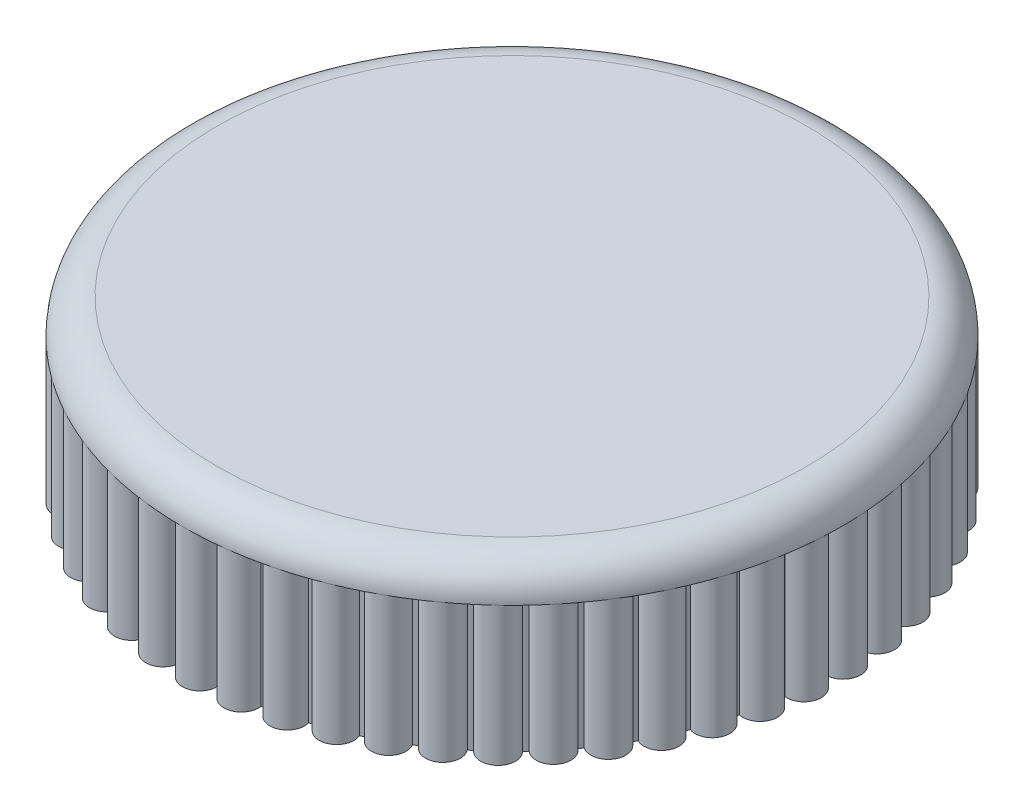
from build123d import *

# Parameters (mm, degrees)
SKETCH1_R           = 24.13
BOSS_EXTRUDE3_DEPTH = 12.7
FILLET2_R           = 2.54
SKETCH4_OUTSIDE_W   = 64.144
SKETCH4_OUTSIDE_H   = 64.144
SKETCH4_OUTSIDE_R   = 22.86
CUT_EXTRUDE3_DEPTH  = 10.16
SKETCH5_R           = 19.05
CUT_EXTRUDE4_DEPTH  = 10.16
SKETCH6_R           = 1.27
BOSS_EXTRUDE7_DEPTH = 10.16
CIRPATTERN1_COUNT   = 50


with BuildPart() as part:
    # Sketch1 → Boss-Extrude3 (new body)
    with BuildSketch(Plane(origin=(0, 0, 0), x_dir=(1, 0, 0), z_dir=(0, 1, 0))):
        Circle(SKETCH1_R)
    extrude(amount=BOSS_EXTRUDE3_DEPTH)

    # Fillet2
    fillet2_edges = [part.edges().sort_by_distance(p)[0] for p in [
        (-24.13, 12.7, 0),
    ]]
    fillet(fillet2_edges, radius=FILLET2_R)

    # Sketch4 outside → Cut-Extrude3 (cut)
    with BuildSketch(Plane(origin=(0, 0, 0), x_dir=(1, 0, 0), z_dir=(0, 1, 0))):
        Rectangle(SKETCH4_OUTSIDE_W, SKETCH4_OUTSIDE_H)
        Circle(SKETCH4_OUTSIDE_R, mode=Mode.SUBTRACT)
    extrude(amount=CUT_EXTRUDE3_DEPTH, mode=Mode.SUBTRACT)

    # Sketch5 → Cut-Extrude4 (cut)
    with BuildSketch(Plane(origin=(0, 0, 0), x_dir=(1, 0, 0), z_dir=(0, 1, 0))):
        Circle(SKETCH5_R)
    extrude(amount=CUT_EXTRUDE4_DEPTH, mode=Mode.SUBTRACT)

    # Sketch6 → Boss-Extrude7 (add)
    with BuildSketch(Plane.XZ):
        with Locations((0, 22.86)):
            Circle(SKETCH6_R)
    boss_extrude7 = extrude(amount=-BOSS_EXTRUDE7_DEPTH)

    # CirPattern1: Boss-Extrude7 ×50 about axis
    cirpattern1_axis = Axis((0, 0, 0), (0, 1, 0))
    for i in range(1, CIRPATTERN1_COUNT):
        add(boss_extrude7.rotate(cirpattern1_axis, i * 360 / CIRPATTERN1_COUNT))


solid = part.part
